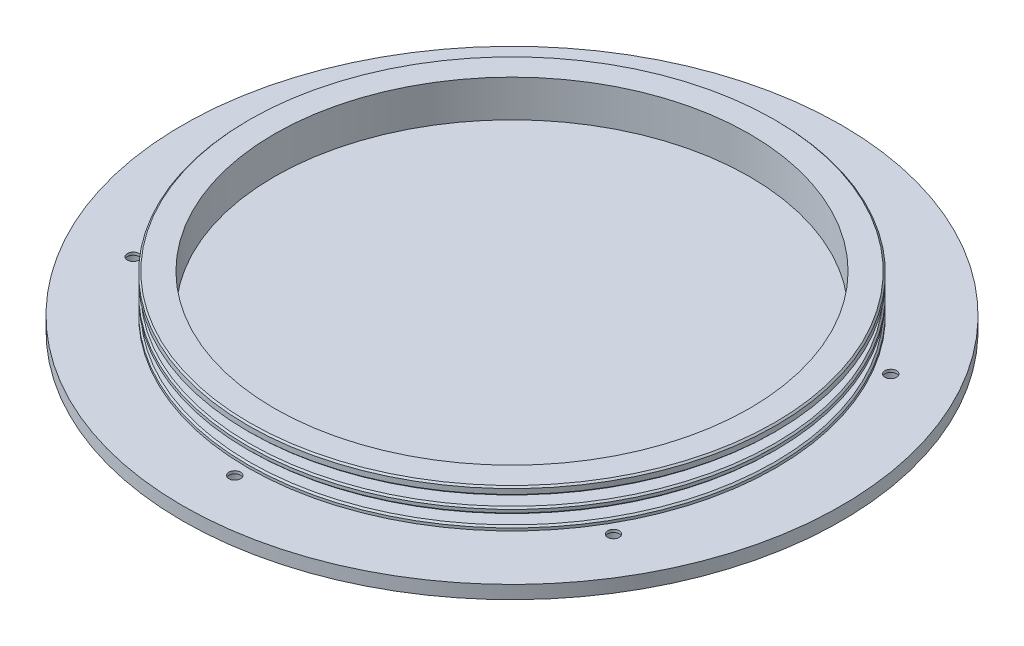
from build123d import *

# Parameters (mm, degrees)
SKETCH1_R                                      = 79.248
EXTRUDE1_DEPTH                                 = 3.175
SKETCH2_R                                      = 63.5
EXTRUDE2_DEPTH                                 = 9.2075
SKETCH4_W                                      = 3.81
SKETCH4_H                                      = 2.3622
CHAMFER1_SIZE                                  = 0.381
SKETCH8_R                                      = 57.15
CUT_EXTRUDE1_DEPTH                             = 8.89
CBORE_FOR_3_SOCKET_HEAD_CAP_SCREW1_D           = 2.794
CBORE_FOR_3_SOCKET_HEAD_CAP_SCREW1_CBORE_D     = 5.15874
CBORE_FOR_3_SOCKET_HEAD_CAP_SCREW1_CBORE_DEPTH = 2.5146
CIRPATTERN1_COUNT                              = 6


with BuildPart() as part:
    # Sketch1 → Extrude1 (new body)
    with BuildSketch(Plane(origin=(0, 0, 0), x_dir=(1, 0, 0), z_dir=(0, 1, 0))):
        Circle(SKETCH1_R)
    extrude(amount=EXTRUDE1_DEPTH)

    # Sketch2 → Extrude2 (add)
    with BuildSketch(Plane(origin=(0, 3.175, 0), x_dir=(-1, 0, 0), z_dir=(0, 1, 0))):
        Circle(SKETCH2_R)
    extrude(amount=EXTRUDE2_DEPTH)

    # Sketch4 → Cut-Revolve7 (revolve, cut)
    with BuildSketch(Plane(origin=(0, 0, 0), x_dir=(0, 0, -1), z_dir=(1, 0, 0))):
        with Locations((-61.595, 9.224034757)):
            Rectangle(SKETCH4_W, SKETCH4_H)
        with Locations((-61.595, 5.360539726)):
            Rectangle(SKETCH4_W, SKETCH4_H)
    revolve(axis=Axis((0, 0, 0), (0, 1, 0)), mode=Mode.SUBTRACT)

    # Chamfer1
    chamfer1_edges = [part.edges().sort_by_distance(p)[0] for p in [
        (63.5, 12.3825, 0),
        (63.5, 4.179439726, 0),
        (63.5, 6.541639726, 0),
        (63.5, 8.042934757, 0),
        (63.5, 10.405134757, 0),
    ]]
    chamfer(chamfer1_edges, length=CHAMFER1_SIZE)

    # Sketch8 → Cut-Extrude1 (cut)
    with BuildSketch(Plane(origin=(0, 12.3825, 0), x_dir=(1, 0, 0), z_dir=(0, 1, 0))):
        Circle(SKETCH8_R)
    extrude(amount=-CUT_EXTRUDE1_DEPTH, mode=Mode.SUBTRACT)

    # CBORE for _3 Socket Head Cap Screw1 (through all)
    with Locations(Plane(origin=(57.742243797, 0, 33.3375), x_dir=(0, 0, -1), z_dir=(0, -1, 0))):
        with Locations((0, 0)):
            cbore_for_3_socket_head_cap_screw1 = CounterBoreHole(CBORE_FOR_3_SOCKET_HEAD_CAP_SCREW1_D / 2, CBORE_FOR_3_SOCKET_HEAD_CAP_SCREW1_CBORE_D / 2, CBORE_FOR_3_SOCKET_HEAD_CAP_SCREW1_CBORE_DEPTH)

    # CirPattern1: CBORE for _3 Socket Head Cap Screw1 ×6 about axis
    cirpattern1_axis = Axis((0, -73.968573618, 0), (0, 1, 0))
    for i in range(1, CIRPATTERN1_COUNT):
        add(cbore_for_3_socket_head_cap_screw1.rotate(cirpattern1_axis, i * 360 / CIRPATTERN1_COUNT), mode=Mode.SUBTRACT)


solid = part.part
